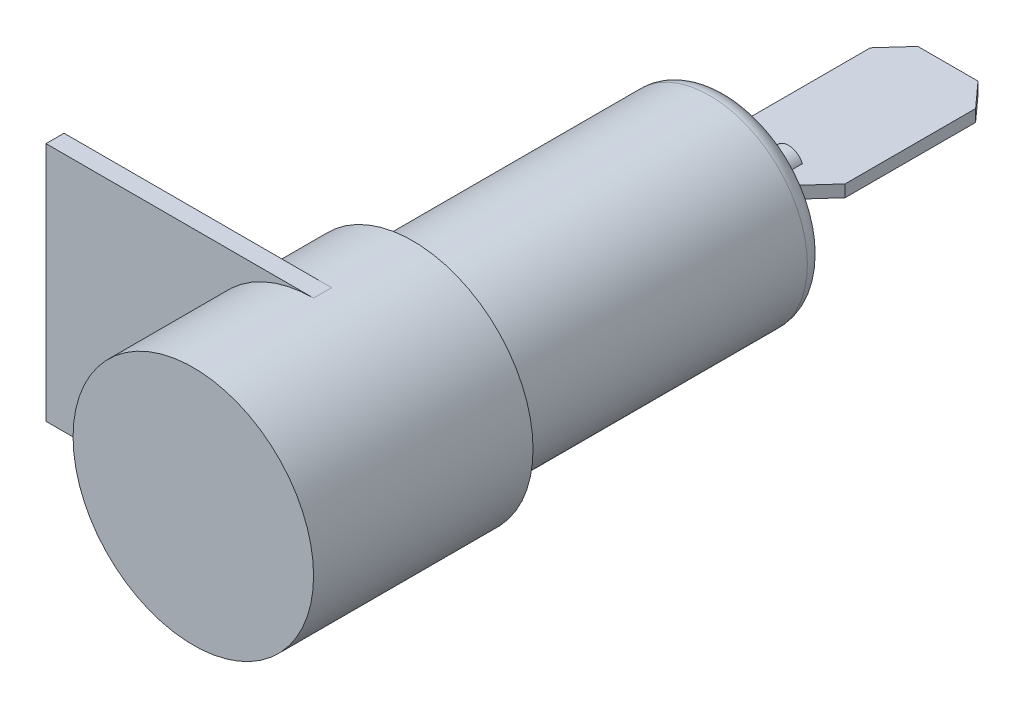
from build123d import *

# Parameters (mm, degrees)
SKETCH3_W           = 17.8
SKETCH3_H           = 16
BOSS_EXTRUDE1_DEPTH = 1.2
BOSS_EXTRUDE2_DEPTH = 0.4


with BuildPart() as part:
    # Sketch2 → Revolve1 (revolve)
    with BuildSketch(Plane(origin=(0, 0, 0), x_dir=(1, 0, 0), z_dir=(0, 1, 0))):
        with BuildLine():
            Line((0, -8), (-8, -8))
            Line((-8, -8), (-8, 6.6))
            Line((-8, 6.6), (-6.5, 6.8))
            Line((-6.5, 6.8), (-6.5, 26.35))
            ThreePointArc((-6.5, 26.35), (-6.133883476, 27.233883476), (-5.25, 27.6))
            Line((-5.25, 27.6), (-1, 27.6))
            Line((-1, 27.6), (-1, 31.6))
            Line((-1, 31.6), (0, 31.6))
            Line((0, 31.6), (0, -8))
        make_face()
    revolve(axis=Axis((0, 0, 8), (0, 0, -1)))

    # Sketch3 → Boss-Extrude1 (add)
    with BuildSketch(Plane.XY):
        with Locations((-8.9, 0)):
            Rectangle(SKETCH3_W, SKETCH3_H)
    extrude(amount=-BOSS_EXTRUDE1_DEPTH)

    # Sketch5 → Boss-Extrude2 (add, symmetric)
    with BuildSketch(Plane(origin=(0, 0, 0), x_dir=(1, 0, 0), z_dir=(0, 1, 0))):
        Polygon((-2, 30.2), (2, 30.2), (3.5, 31.859853002), (3.5, 40.540146998), (2, 42.2), (-2, 42.2), (-3.5, 40.540146998), (-3.5, 31.859853002), align=None)
    extrude(amount=BOSS_EXTRUDE2_DEPTH, both=True)


solid = part.part
